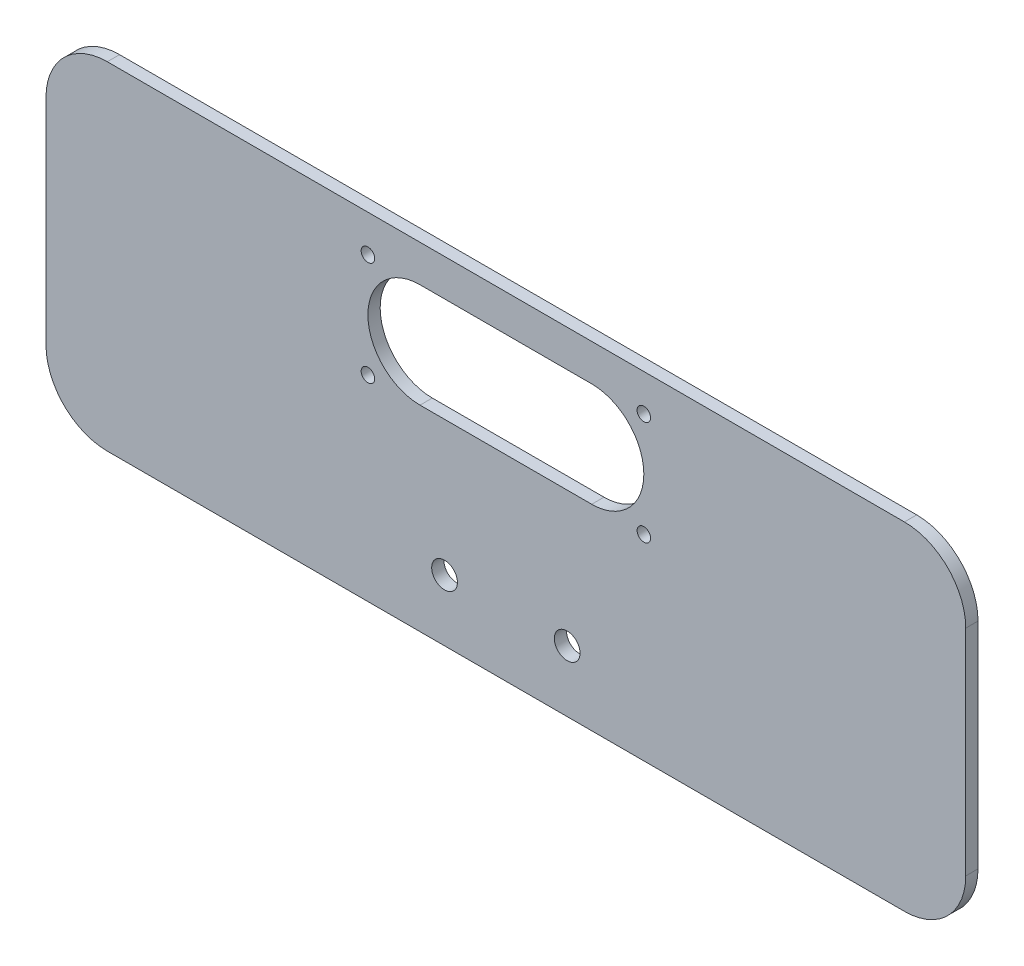
from build123d import *

# Parameters (mm, degrees)
SKETCH_1_R      = 2.1
SKETCH_1_R_2    = 1.1
EXTRUDE_1_DEPTH = 2


with BuildPart() as part:
    # 草图1 → 凸台-拉伸1 (new body)
    with BuildSketch(Plane.XY):
        with BuildLine():
            Line((-65, 27.5), (65, 27.5))
            ThreePointArc((65, 27.5), (72.071067812, 24.571067812), (75, 17.5))
            Line((75, 17.5), (75, -17.5))
            ThreePointArc((75, -17.5), (72.071067812, -24.571067812), (65, -27.5))
            Line((65, -27.5), (-65, -27.5))
            ThreePointArc((-65, -27.5), (-72.071067812, -24.571067812), (-75, -17.5))
            Line((-75, -17.5), (-75, 17.5))
            ThreePointArc((-75, 17.5), (-72.071067812, 24.571067812), (-65, 27.5))
        make_face()
        with Locations((-10, -17.5)):
            Circle(SKETCH_1_R, mode=Mode.SUBTRACT)
        with Locations((10, -17.5)):
            Circle(SKETCH_1_R, mode=Mode.SUBTRACT)
        with Locations((-22.5, 21.5)):
            Circle(SKETCH_1_R_2, mode=Mode.SUBTRACT)
        with Locations((-22.5, 4.5)):
            Circle(SKETCH_1_R_2, mode=Mode.SUBTRACT)
        with Locations((22.5, 4.5)):
            Circle(SKETCH_1_R_2, mode=Mode.SUBTRACT)
        with Locations((22.5, 21.5)):
            Circle(SKETCH_1_R_2, mode=Mode.SUBTRACT)
        with BuildLine():
            Line((-14, 21.5), (14, 21.5))
            ThreePointArc((14, 21.5), (22.5, 13), (14, 4.5))
            Line((14, 4.5), (-14, 4.5))
            ThreePointArc((-14, 4.5), (-22.5, 13), (-14, 21.5))
        make_face(mode=Mode.SUBTRACT)
    extrude(amount=EXTRUDE_1_DEPTH)


solid = part.part
